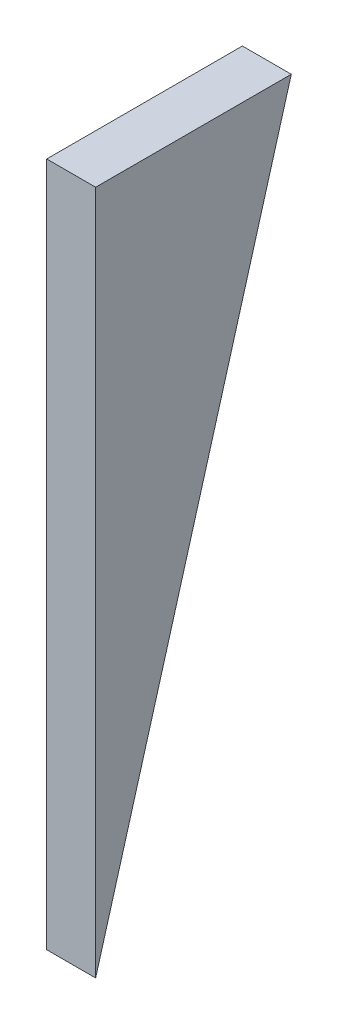
from build123d import *

# Parameters (mm, degrees)
BOSS_EXTRUDE1_DEPTH = 6.35


with BuildPart() as part:
    # Sketch2 → Boss-Extrude1 (new body, symmetric)
    with BuildSketch(Plane(origin=(0, 0, 0), x_dir=(0, 0, -1), z_dir=(1, 0, 0))):
        Polygon((0, 88.9), (50.8, 88.9), (0, -88.9), align=None)
    extrude(amount=BOSS_EXTRUDE1_DEPTH, both=True)


solid = part.part
